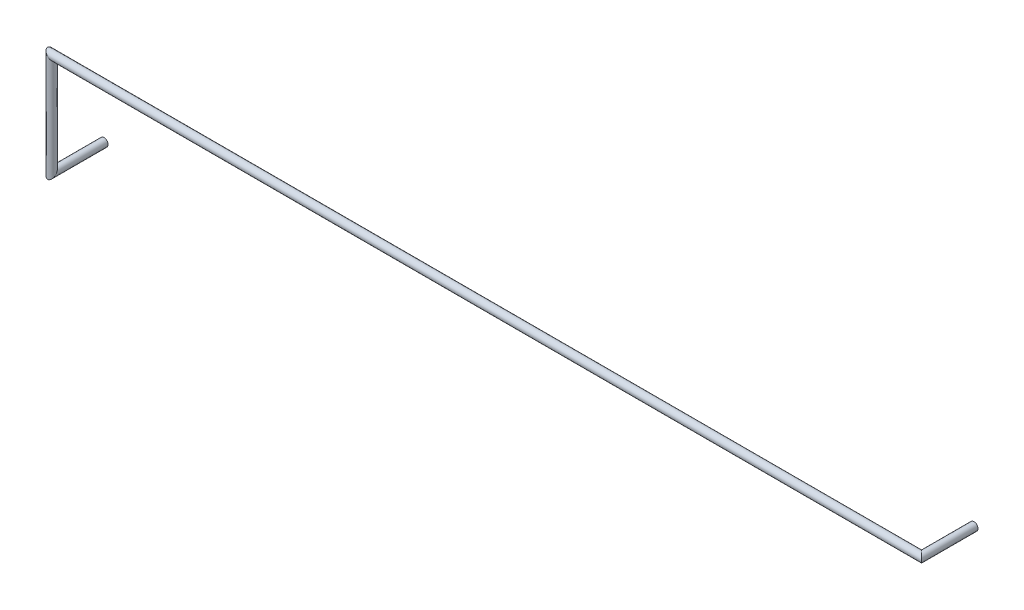
from build123d import *

# Parameters (mm, degrees)
SWEEP1_PROFILE_R = 0.2


with BuildPart() as part:
    # Sweep1: sweep along a curve in space
    with BuildLine() as sweep1_path:
        Line((0, 0, 0), (0, 0, 2.6))
        Line((0, 0, 2.6), (0, 5.08, 2.6))
        Line((0, 5.08, 2.6), (43.18, 5.08, 2.6))
        Line((43.18, 5.08, 2.6), (43.18, 5.08, 0))
    # Sweep1 profile (on start of the path) → Sweep1 (sweep)
    with BuildSketch(Plane.XY):
        Circle(SWEEP1_PROFILE_R)
    sweep(path=sweep1_path.line, transition=Transition.RIGHT)


solid = part.part
